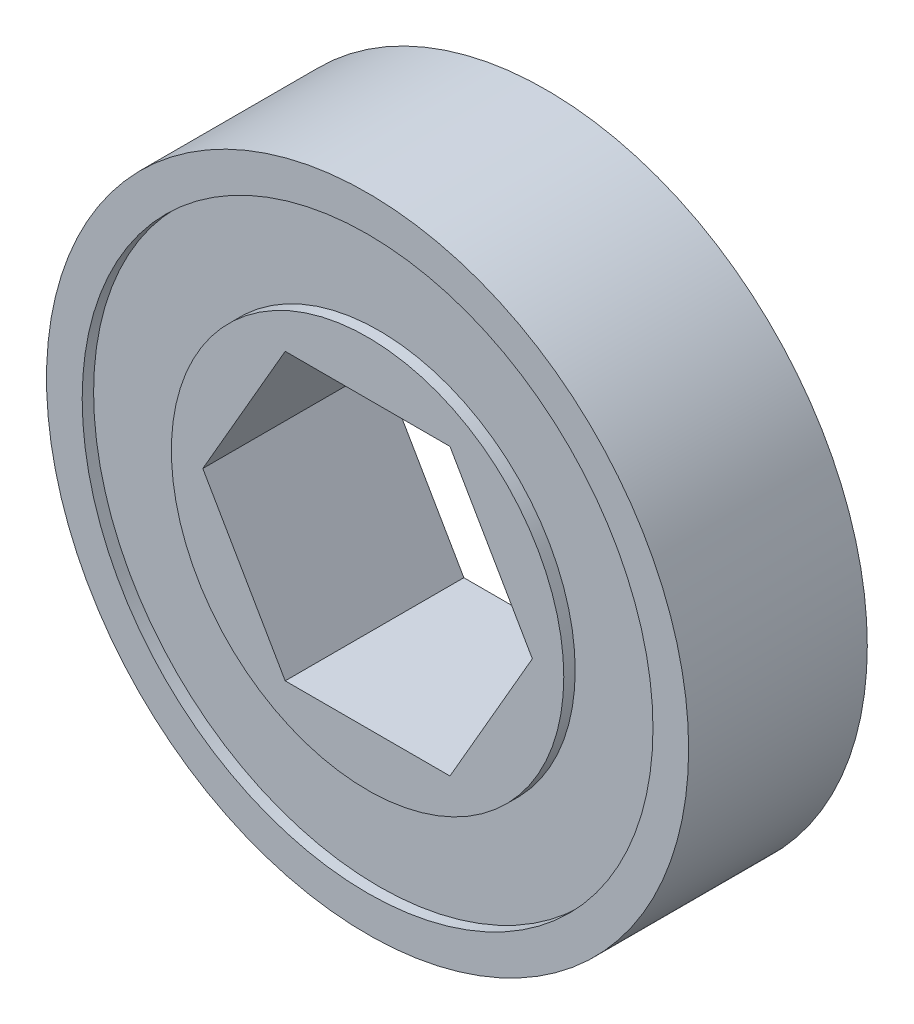
from build123d import *

# Parameters (mm, degrees)
SKETCH1_R           = 14.2875
BOSS_EXTRUDE1_DEPTH = 3.9751
SKETCH2_R           = 12.7
SKETCH2_R_2         = 8.73125
CUT_EXTRUDE1_DEPTH  = 0.508


with BuildPart() as part:
    # Sketch1 → Boss-Extrude1 (new body, symmetric)
    with BuildSketch(Plane.XY):
        Circle(SKETCH1_R)
        Polygon((7.332348419, 0), (3.666174209, 6.35), (-3.666174209, 6.35), (-7.332348419, 0), (-3.666174209, -6.35), (3.666174209, -6.35), align=None, mode=Mode.SUBTRACT)
    extrude(amount=BOSS_EXTRUDE1_DEPTH, both=True)

    # Sketch2 → Cut-Extrude1 (cut)
    with BuildSketch(Plane.XY.offset(3.9751)):
        Circle(SKETCH2_R)
        Circle(SKETCH2_R_2, mode=Mode.SUBTRACT)
    cut_extrude1 = extrude(amount=-CUT_EXTRUDE1_DEPTH, mode=Mode.SUBTRACT)

    # Mirror1: Cut-Extrude1 across plane
    add(cut_extrude1.mirror(Plane.XY), mode=Mode.SUBTRACT)


solid = part.part
